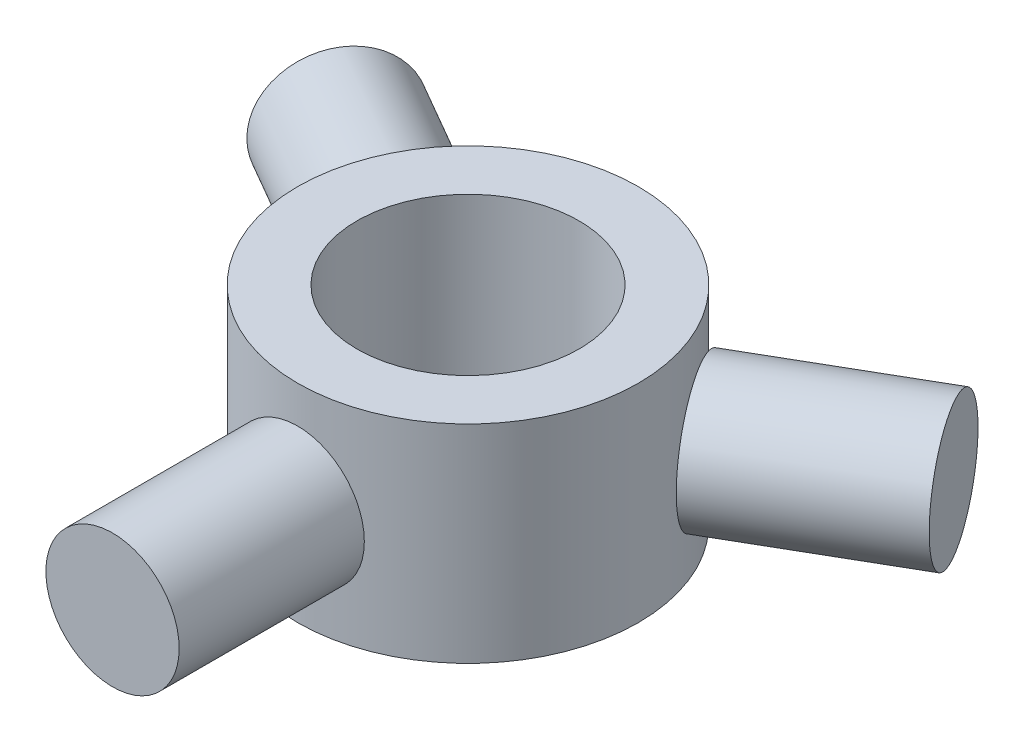
from build123d import *

# Parameters (mm, degrees)
BOSS_EXTRU_1_DEPTH           = 14
BOSS_EXTRU_1_DEPTH_BACK      = 14
ESQUISSE1_R                  = 23
ESQUISSE1_R_2                = 15
ESQUISSE2_R                  = 9
BOSS_EXTRU_2_DEPTH           = 25
R_P_TITION_CIRCULAIRE6_COUNT = 3


with BuildPart() as part:
    # Esquisse1 → Boss.-Extru.1 (new, two sides: drawn at the far end of the back side and taken through both)
    with BuildSketch(Plane(origin=(0, 0, 0), x_dir=(1, 0, 0), z_dir=(0, 1, 0)).offset(-BOSS_EXTRU_1_DEPTH_BACK)):
        Circle(ESQUISSE1_R)
        Circle(ESQUISSE1_R_2, mode=Mode.SUBTRACT)
    extrude(amount=BOSS_EXTRU_1_DEPTH + BOSS_EXTRU_1_DEPTH_BACK)


with BuildPart() as body_2:
    # Esquisse2 → Boss.-Extru.2 (new body)
    with BuildSketch(Plane.XY.offset(23)):
        Circle(ESQUISSE2_R)
    extrude(amount=BOSS_EXTRU_2_DEPTH)


with BuildPart() as r_p_tition_circulaire6_1:
    # Répétition circulaire6: pattern copy
    add(body_2.part.rotate(Axis((0, -14, 0), (0, 1, 0)), 1 * 360 / R_P_TITION_CIRCULAIRE6_COUNT))


with BuildPart() as r_p_tition_circulaire6_2:
    # Répétition circulaire6: pattern copy
    add(body_2.part.rotate(Axis((0, -14, 0), (0, 1, 0)), 2 * 360 / R_P_TITION_CIRCULAIRE6_COUNT))


solid = Compound([part.part, body_2.part, r_p_tition_circulaire6_1.part, r_p_tition_circulaire6_2.part])
